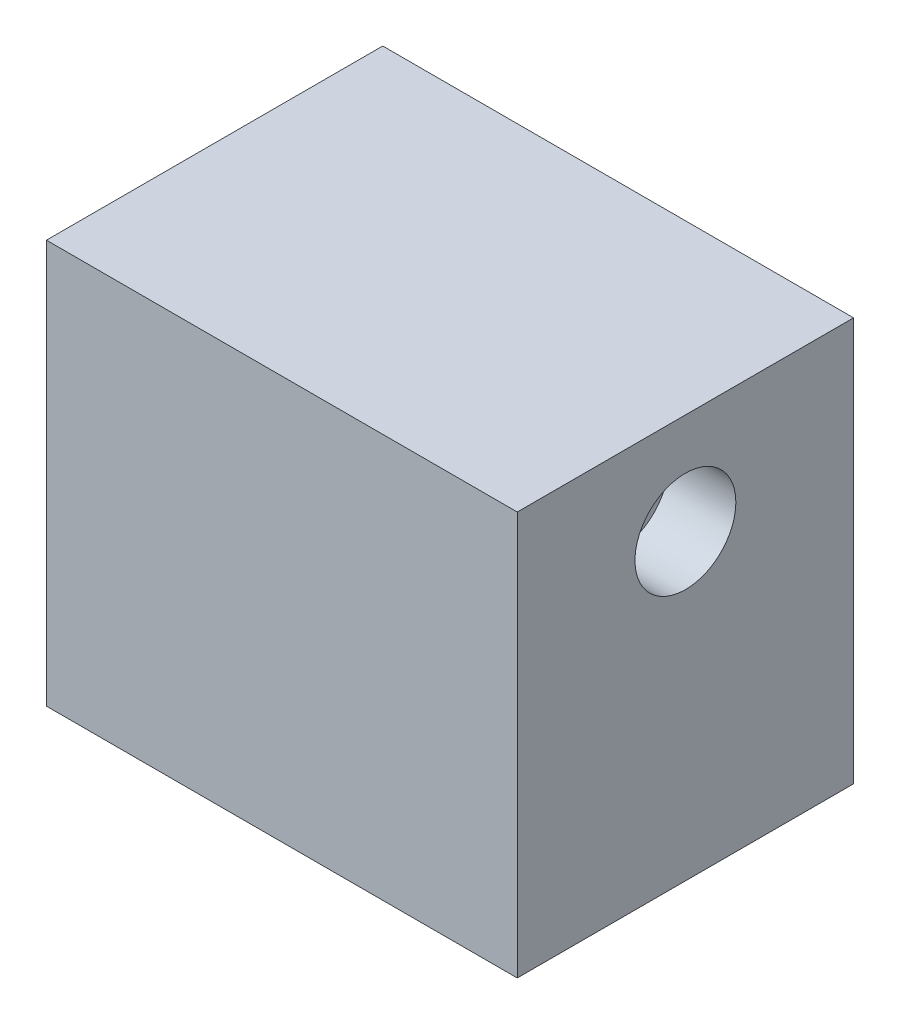
from build123d import *

# Parameters (mm, degrees)
SKETCH1_W           = 35
SKETCH1_H           = 25
BOSS_EXTRUDE1_DEPTH = 30
SKETCH2_R           = 3.75
CUT_EXTRUDE1_DEPTH  = 5
SKETCH3_R           = 3.75
CUT_EXTRUDE2_DEPTH  = 5


with BuildPart() as part:
    # Sketch1 → Boss-Extrude1 (new body)
    with BuildSketch(Plane(origin=(0, 0, 0), x_dir=(1, 0, 0), z_dir=(0, 1, 0))):
        with Locations((17.5, 12.5)):
            Rectangle(SKETCH1_W, SKETCH1_H)
    extrude(amount=BOSS_EXTRUDE1_DEPTH)

    # Sketch2 → Cut-Extrude1 (cut)
    with BuildSketch(Plane(origin=(35, 0, 0), x_dir=(0, 0, -1), z_dir=(1, 0, 0))):
        with Locations((12.5, 22.5)):
            Circle(SKETCH2_R)
    extrude(amount=-CUT_EXTRUDE1_DEPTH, mode=Mode.SUBTRACT)

    # Sketch3 → Cut-Extrude2 (cut)
    with BuildSketch(Plane.ZY):
        with Locations((-12.5, 22.5)):
            Circle(SKETCH3_R)
    extrude(amount=-CUT_EXTRUDE2_DEPTH, mode=Mode.SUBTRACT)


solid = part.part
